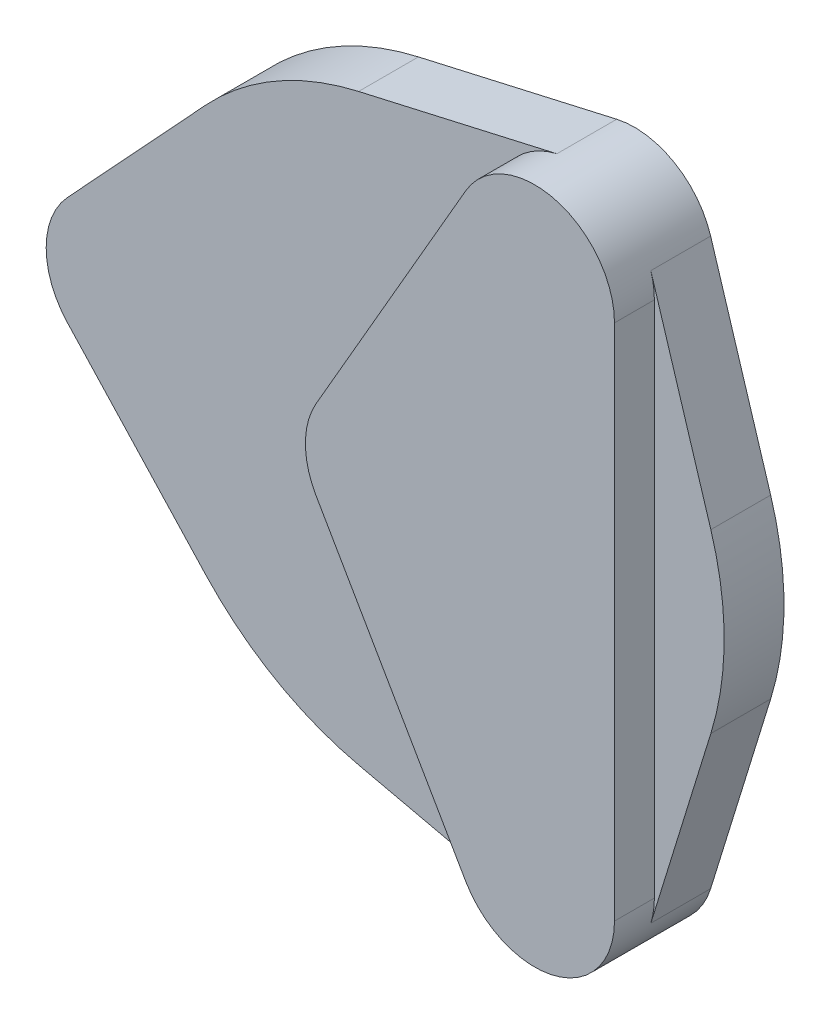
from build123d import *

# Parameters (mm, degrees)
EXTRUDE_1_DEPTH = 6
EXTRUDE_2_DEPTH = 10


with BuildPart() as part:
    # 草圖1 → 填料-伸長1 (new body)
    with BuildSketch(Plane.XY):
        with BuildLine():
            Line((-22, 20.396078054), (-35.866666667, 5.438954148))
            ThreePointArc((-35.866666667, 5.438954148), (-38, 0), (-35.866666667, -5.438954148))
            Line((-35.866666667, -5.438954148), (-22, -20.396078054))
            ThreePointArc((-22, -20.396078054), (-15, -25.980762114), (-6.663521733, -29.25059791))
            Line((-6.663521733, -29.25059791), (13.223060871, -33.780921556))
            ThreePointArc((13.223060871, -33.780921556), (19, -32.908965344), (22.643605795, -28.341967408))
            Line((22.643605795, -28.341967408), (28.663521733, -8.854519856))
            ThreePointArc((28.663521733, -8.854519856), (30, 0), (28.663521733, 8.854519856))
            Line((28.663521733, 8.854519856), (22.643605795, 28.341967408))
            ThreePointArc((22.643605795, 28.341967408), (19, 32.908965344), (13.223060871, 33.780921556))
            Line((13.223060871, 33.780921556), (-6.663521733, 29.25059791))
            ThreePointArc((-6.663521733, 29.25059791), (-15, 25.980762114), (-22, 20.396078054))
        make_face()
    extrude(amount=EXTRUDE_1_DEPTH)

    # 草圖3 → 填料-伸長2 (add)
    with BuildSketch(Plane.XY):
        with BuildLine():
            Line((8.07179677, 29.980762114), (-6.92820323, 4))
            ThreePointArc((-6.92820323, 4), (-8, 0), (-6.92820323, -4))
            Line((-6.92820323, -4), (8.07179677, -29.980762114))
            ThreePointArc((8.07179677, -29.980762114), (17.070552361, -33.708168724), (23, -25.980762114))
            Line((23, -25.980762114), (23, 25.980762114))
            ThreePointArc((23, 25.980762114), (17.070552361, 33.708168724), (8.07179677, 29.980762114))
        make_face()
    extrude(amount=EXTRUDE_2_DEPTH)


solid = part.part
